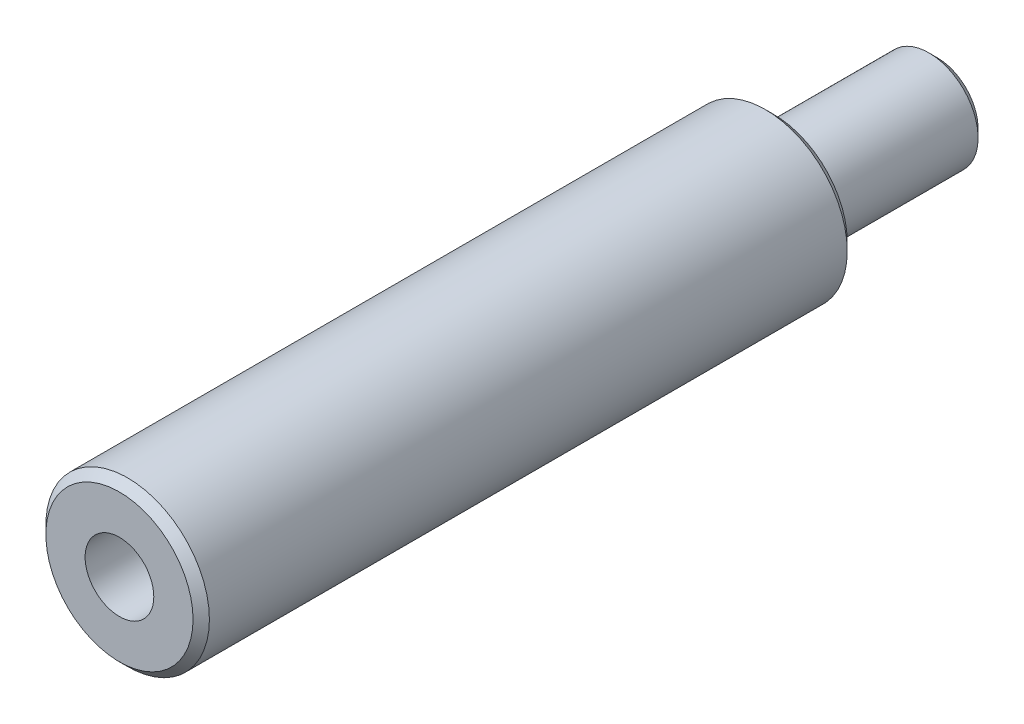
from build123d import *

# Parameters (mm, degrees)
ESQUISSE1_R                                   = 5
BOSS_EXTRU_1_DEPTH                            = 40
ESQUISSE2_R                                   = 3
BOSS_EXTRU_2_DEPTH                            = 10
TROU_POUR_TARAUDAGE_POUR_TROU_TARAUD_M5_D     = 4.2
TROU_POUR_TARAUDAGE_POUR_TROU_TARAUD_M5_DEPTH = 10
TROU_POUR_TARAUDAGE_POUR_TROU_TARAUD_M5_TIP   = 1.2618073
CHANFREIN1_SIZE                               = 0.5


with BuildPart() as part:
    # Esquisse1 → Boss.-Extru.1 (new body)
    with BuildSketch(Plane.XY):
        Circle(ESQUISSE1_R)
    extrude(amount=BOSS_EXTRU_1_DEPTH)

    # Esquisse2 → Boss.-Extru.2 (add)
    with BuildSketch(Plane(origin=(0, 0, 0), x_dir=(-1, 0, 0), z_dir=(0, 0, -1))):
        Circle(ESQUISSE2_R)
    extrude(amount=BOSS_EXTRU_2_DEPTH)

    # Trou pour taraudage pour trou taraudé M51
    with Locations(Plane.XY.offset(40)):
        with Locations((0, 0)):
            Hole(TROU_POUR_TARAUDAGE_POUR_TROU_TARAUD_M5_D / 2, depth=TROU_POUR_TARAUDAGE_POUR_TROU_TARAUD_M5_DEPTH)
            with Locations((0, 0, -(TROU_POUR_TARAUDAGE_POUR_TROU_TARAUD_M5_DEPTH + TROU_POUR_TARAUDAGE_POUR_TROU_TARAUD_M5_TIP / 2))):  # 118° drill point
                Cone(0, TROU_POUR_TARAUDAGE_POUR_TROU_TARAUD_M5_D / 2, TROU_POUR_TARAUDAGE_POUR_TROU_TARAUD_M5_TIP, mode=Mode.SUBTRACT)

    # Chanfrein1
    chanfrein1_edges = [part.edges().sort_by_distance(p)[0] for p in [
        (-5, 0, 0),
        (-5, 0, 40),
        (3, 0, -10),
    ]]
    chamfer(chanfrein1_edges, length=CHANFREIN1_SIZE)


solid = part.part
